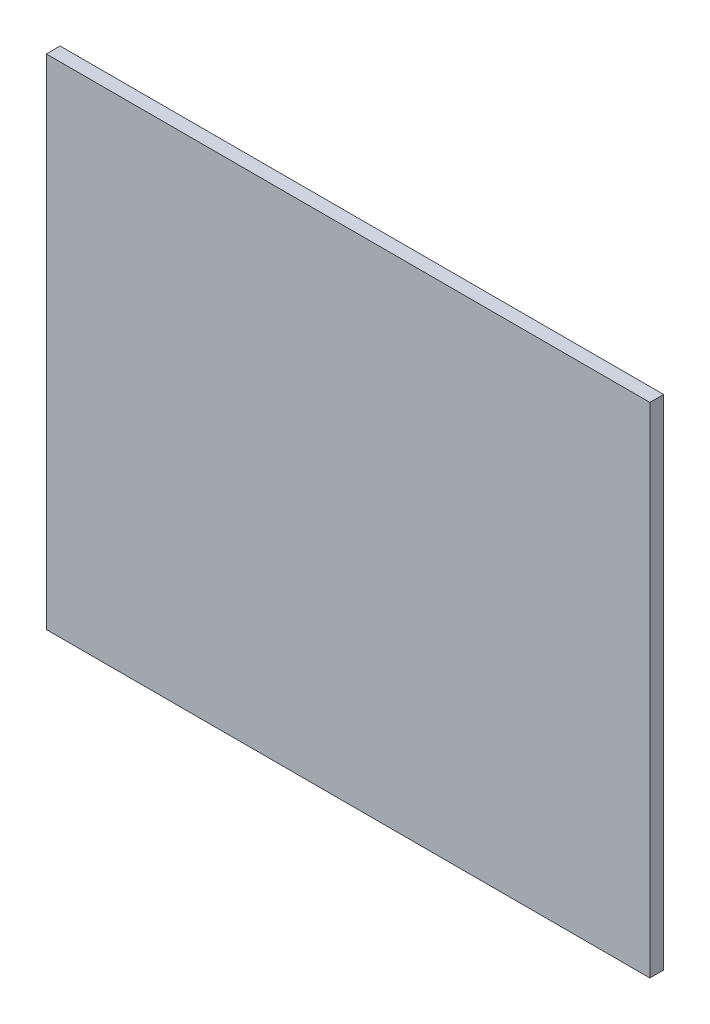
from build123d import *

# Parameters (mm, degrees)
SKETCH1_W           = 69.5
SKETCH1_H           = 57.404
BOSS_EXTRUDE1_DEPTH = 1.5875


with BuildPart() as part:
    # Sketch1 → Boss-Extrude1 (new body)
    with BuildSketch(Plane.XY):
        with Locations((12.077133479, 2.930930267)):
            Rectangle(SKETCH1_W, SKETCH1_H)
    extrude(amount=BOSS_EXTRUDE1_DEPTH)


solid = part.part
